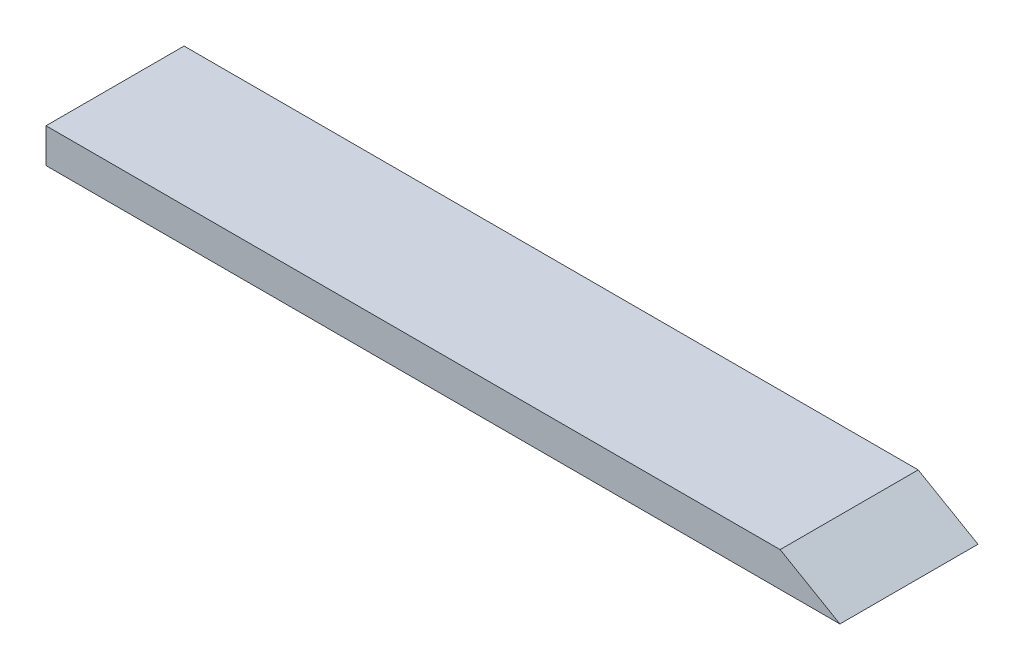
from build123d import *

# Parameters (mm, degrees)
SKETCH1_W           = 115
SKETCH1_H           = 20
BOSS_EXTRUDE1_DEPTH = 5
CUT_EXTRUDE1_DEPTH  = 21


with BuildPart() as part:
    # Sketch1 → Boss-Extrude1 (new body)
    with BuildSketch(Plane(origin=(0, 0, 0), x_dir=(1, 0, 0), z_dir=(0, 1, 0))):
        Rectangle(SKETCH1_W, SKETCH1_H)
    extrude(amount=BOSS_EXTRUDE1_DEPTH)

    # Sketch2 → Cut-Extrude1 (cut, through all)
    with BuildSketch(Plane.XY.offset(10)):
        Polygon((57.5, 0), (48.839745962, 5), (57.5, 5), align=None)
    extrude(amount=-CUT_EXTRUDE1_DEPTH, mode=Mode.SUBTRACT)


solid = part.part
